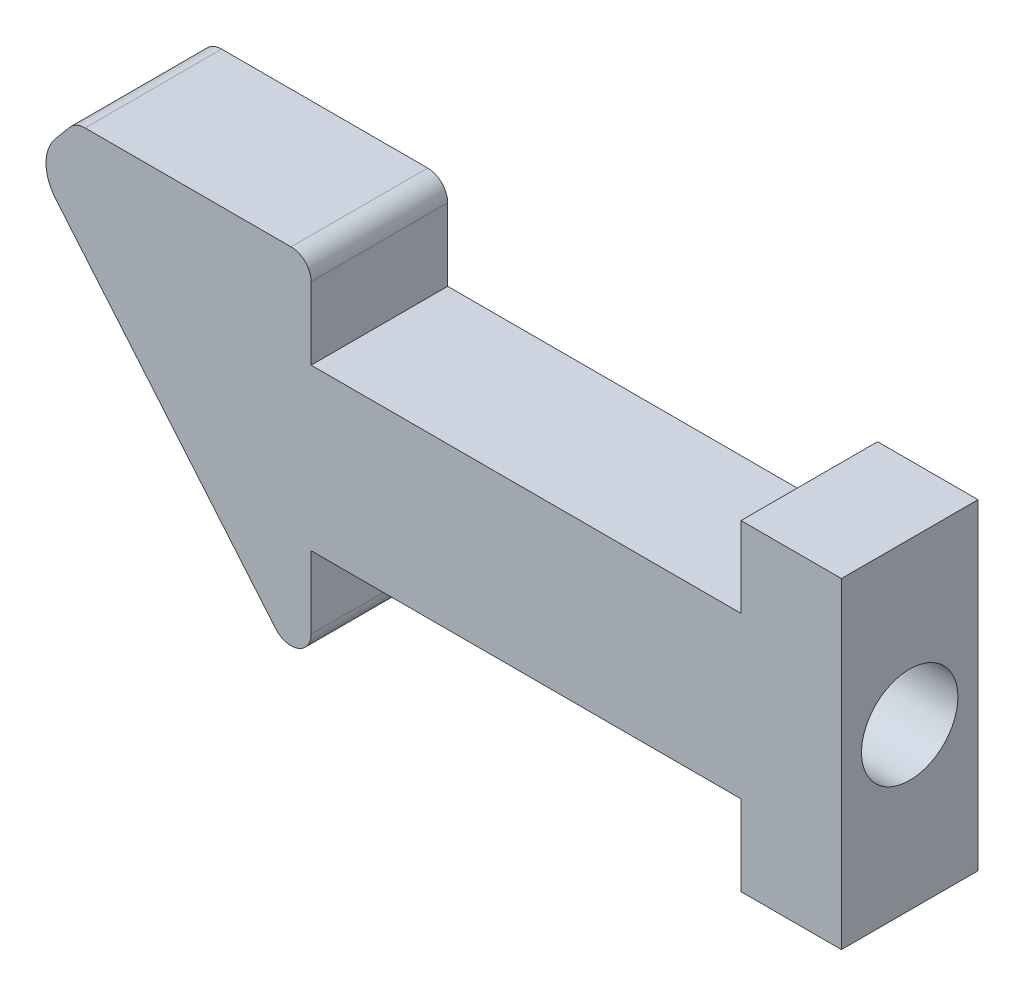
from build123d import *

# Parameters (mm, degrees)
BOSS_EXTRUDE3_DEPTH = 1.7
SKETCH3_R           = 0.95
CUT_EXTRUDE1_DEPTH  = 9.5
SKETCH4_R           = 1.2
CUT_EXTRUDE2_DEPTH  = 2.8


with BuildPart() as part:
    # Sketch2 → Boss-Extrude3 (new body, symmetric)
    with BuildSketch(Plane.XY):
        with BuildLine():
            Line((-18.828250092, 4.3), (-13.7, 4.3))
            ThreePointArc((-13.7, 4.3), (-13.346446609, 4.153553391), (-13.2, 3.8))
            Line((-13.2, 3.8), (-13.2, 2))
            Line((-13.2, 2), (-2.5, 2))
            Line((-2.5, 2), (-2.5, 4))
            Line((-2.5, 4), (0, 4))
            Line((0, 4), (0, -4))
            Line((0, -4), (-2.5, -4))
            Line((-2.5, -4), (-2.5, -2))
            Line((-2.5, -2), (-13.2, -2))
            Line((-13.2, -2), (-13.2, -3.8))
            ThreePointArc((-13.2, -3.8), (-13.528989928, -4.26984631), (-14.083022222, -4.121393805))
            Line((-14.083022222, -4.121393805), (-19.566044443, 2.413017626))
            ThreePointArc((-19.566044443, 2.413017626), (-19.8, 3.055805236), (-19.566044443, 3.698592845))
            Line((-19.566044443, 3.698592845), (-19.211272314, 4.121393805))
            ThreePointArc((-19.211272314, 4.121393805), (-19.039559223, 4.253153894), (-18.828250092, 4.3))
        make_face()
    extrude(amount=BOSS_EXTRUDE3_DEPTH, both=True)

    # Sketch3 → Cut-Extrude1 (cut)
    with BuildSketch(Plane(origin=(0, 0, 0), x_dir=(0, 0, -1), z_dir=(1, 0, 0))):
        Circle(SKETCH3_R)
    extrude(amount=-CUT_EXTRUDE1_DEPTH, mode=Mode.SUBTRACT)

    # Sketch4 → Cut-Extrude2 (cut)
    with BuildSketch(Plane(origin=(0, 0, 0), x_dir=(0, 0, -1), z_dir=(1, 0, 0))):
        Circle(SKETCH4_R)
    extrude(amount=-CUT_EXTRUDE2_DEPTH, mode=Mode.SUBTRACT)


solid = part.part
